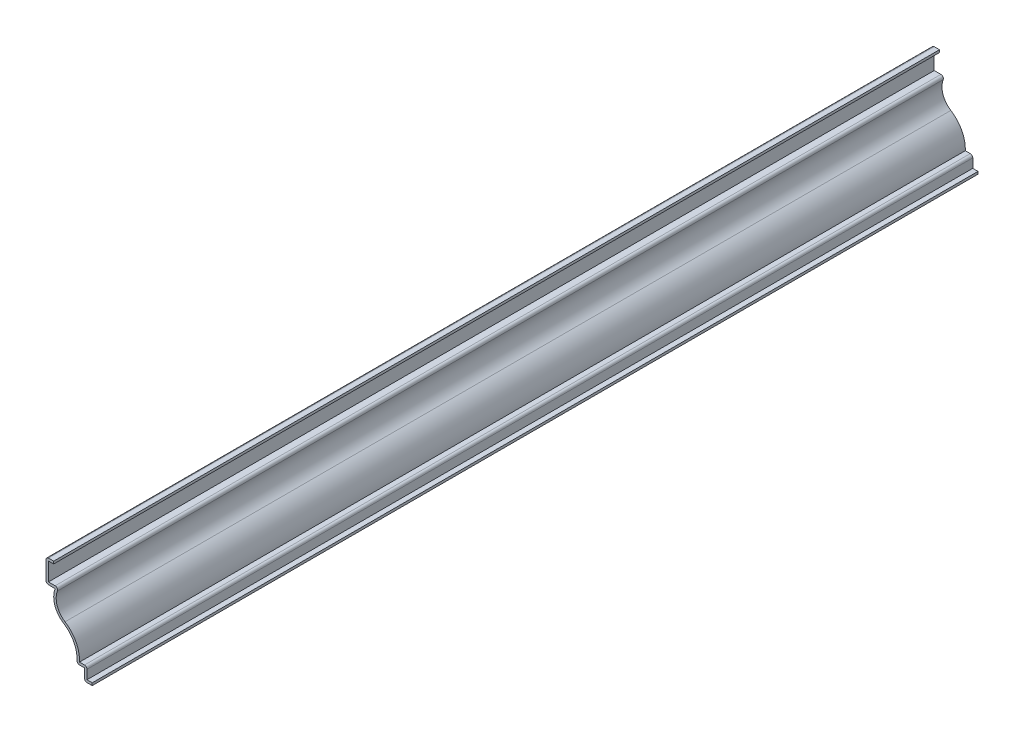
from build123d import *

# Parameters (mm, degrees)
EXTRUDE_THIN1_DEPTH = 365.125
FILLET1_R           = 1.016


with BuildPart() as part:
    # Sketch1 → Extrude-Thin1 (new body)
    with BuildSketch(Plane.XY):
        with BuildLine():
            Line((0, 0), (-3.175, 0))
            Line((-3.175, 0), (-3.175, 4.7625))
            Line((-3.175, 4.7625), (-6.35, 4.7625))
            ThreePointArc((-6.35, 4.7625), (-7.348495491, 11.335579769), (-11.744129794, 16.323642516))
            ThreePointArc((-11.744129794, 16.323642516), (-15.423635055, 21.021661297), (-15.286128704, 26.9875))
            Line((-15.286128704, 26.9875), (-19.05, 26.9875))
            Line((-19.05, 26.9875), (-19.05, 36.5125))
            Line((-19.05, 36.5125), (-15.875, 36.5125))
            Line((-15.875, 36.5125), (-15.875, 35.4965))
            Line((-15.875, 35.4965), (-18.034, 35.4965))
            Line((-18.034, 35.4965), (-18.034, 28.0035))
            Line((-18.034, 28.0035), (-13.644372615, 28.0035))
            ThreePointArc((-13.644372615, 28.0035), (-14.6666845, 22.086915467), (-11.202164171, 17.18301977))
            ThreePointArc((-11.202164171, 17.18301977), (-6.684331546, 12.284081572), (-5.239404036, 5.7785))
            Line((-5.239404036, 5.7785), (-2.159, 5.7785))
            Line((-2.159, 5.7785), (-2.159, 1.016))
            Line((-2.159, 1.016), (0, 1.016))
            Line((0, 1.016), (0, 0))
        make_face()
    extrude(amount=-EXTRUDE_THIN1_DEPTH)

    # Fillet1
    fillet1_edges = [part.edges().sort_by_distance(p)[0] for p in [
        (-13.644372615, 28.0035, -182.5625),
        (-2.159, 5.7785, -182.5625),
        (-3.175, 0, -182.5625),
        (-6.35, 4.7625, -182.5625),
        (-19.05, 26.9875, -182.5625),
        (-19.05, 36.5125, -182.5625),
    ]]
    fillet(fillet1_edges, radius=FILLET1_R)


solid = part.part
